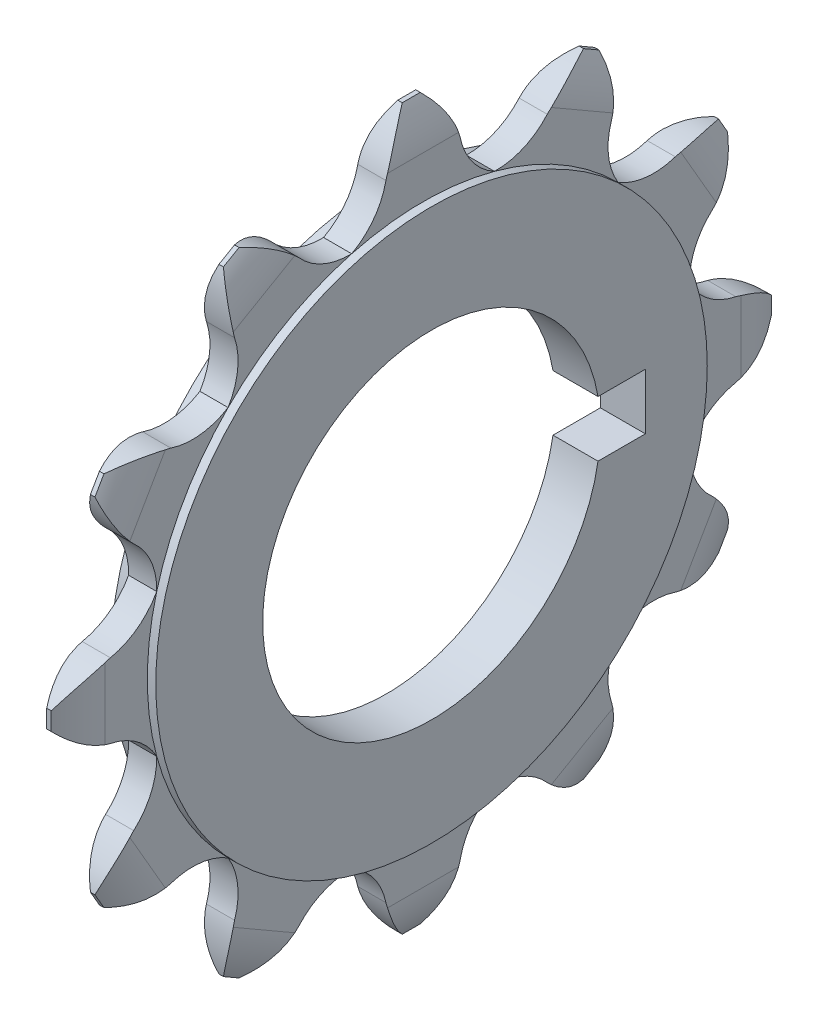
from build123d import *

# Parameters (mm, degrees)
BOSS_EXTRUDE1_DEPTH     = 3.175
CUT_EXTRUDE1_DEPTH      = 17.106309177
CUT_EXTRUDE1_DEPTH_BACK = 17.106309177
CIRPATTERN1_COUNT       = 12
SKETCH6_R               = 62.23
SKETCH6_R_2             = 38.1
BOSS_EXTRUDE2_DEPTH     = 5.08
SKETCH7_W               = 20.32
SKETCH7_H               = 12.621911528
CUT_EXTRUDE2_DEPTH      = 6.08
CUT_EXTRUDE2_DEPTH_BACK = 6.08


with BuildPart() as part:
    # Sketch4 → Boss-Extrude1 (new body, symmetric)
    with BuildSketch(Plane(origin=(0, 0, 0), x_dir=(0, 0, -1), z_dir=(1, 0, 0))):
        with BuildLine():
            Line((-2.032, 81.255567884), (2.032, 81.255567884))
            ThreePointArc((2.032, 81.255567884), (5.928090971, 76.340921265), (8.382, 70.56930046))
            ThreePointArc((8.382, 70.56930046), (11.0866932, 64.484669884), (16.106309177, 60.10956417))
            ThreePointArc((16.106309177, 60.10956417), (0, 62.23), (-16.106309177, 60.10956417))
            ThreePointArc((-16.106309177, 60.10956417), (-11.0866932, 64.484669884), (-8.382, 70.56930046))
            ThreePointArc((-8.382, 70.56930046), (-5.928090971, 76.340921265), (-2.032, 81.255567884))
        make_face()
    extrude(amount=BOSS_EXTRUDE1_DEPTH, both=True)

    # Sketch5 → Cut-Extrude1 (cut, two sides)
    with BuildSketch(Plane.XY) as cut_extrude1_sk:
        with BuildLine():
            Line((-0.508, 81.255567884), (0.508, 81.255567884))
            ThreePointArc((0.508, 81.255567884), (2.579341226, 76.096579157), (3.175, 70.56930046))
            Line((3.175, 70.56930046), (13.239002465, 70.56930046))
            Line((13.239002465, 70.56930046), (13.239002465, 94.490077883))
            Line((13.239002465, 94.490077883), (-20.321800896, 94.490077883))
            Line((-20.321800896, 94.490077883), (-20.321800896, 70.56930046))
            Line((-20.321800896, 70.56930046), (-3.175, 70.56930046))
            ThreePointArc((-3.175, 70.56930046), (-2.579341226, 76.096579157), (-0.508, 81.255567884))
        make_face()
    extrude(amount=CUT_EXTRUDE1_DEPTH, mode=Mode.SUBTRACT)
    extrude(cut_extrude1_sk.sketch, amount=-CUT_EXTRUDE1_DEPTH_BACK, mode=Mode.SUBTRACT)


with BuildPart() as cirpattern1_1:
    # CirPattern1: pattern copy
    add(part.part.rotate(Axis((0, 0, 0), (1, 0, 0)), 1 * 360 / CIRPATTERN1_COUNT))


with BuildPart() as cirpattern1_2:
    # CirPattern1: pattern copy
    add(part.part.rotate(Axis((0, 0, 0), (1, 0, 0)), 2 * 360 / CIRPATTERN1_COUNT))


with BuildPart() as cirpattern1_3:
    # CirPattern1: pattern copy
    add(part.part.rotate(Axis((0, 0, 0), (1, 0, 0)), 3 * 360 / CIRPATTERN1_COUNT))


with BuildPart() as cirpattern1_4:
    # CirPattern1: pattern copy
    add(part.part.rotate(Axis((0, 0, 0), (1, 0, 0)), 4 * 360 / CIRPATTERN1_COUNT))


with BuildPart() as cirpattern1_5:
    # CirPattern1: pattern copy
    add(part.part.rotate(Axis((0, 0, 0), (1, 0, 0)), 5 * 360 / CIRPATTERN1_COUNT))


with BuildPart() as cirpattern1_6:
    # CirPattern1: pattern copy
    add(part.part.rotate(Axis((0, 0, 0), (1, 0, 0)), 6 * 360 / CIRPATTERN1_COUNT))


with BuildPart() as cirpattern1_7:
    # CirPattern1: pattern copy
    add(part.part.rotate(Axis((0, 0, 0), (1, 0, 0)), 7 * 360 / CIRPATTERN1_COUNT))


with BuildPart() as cirpattern1_8:
    # CirPattern1: pattern copy
    add(part.part.rotate(Axis((0, 0, 0), (1, 0, 0)), 8 * 360 / CIRPATTERN1_COUNT))


with BuildPart() as cirpattern1_9:
    # CirPattern1: pattern copy
    add(part.part.rotate(Axis((0, 0, 0), (1, 0, 0)), 9 * 360 / CIRPATTERN1_COUNT))


with BuildPart() as cirpattern1_10:
    # CirPattern1: pattern copy
    add(part.part.rotate(Axis((0, 0, 0), (1, 0, 0)), 10 * 360 / CIRPATTERN1_COUNT))


with BuildPart() as cirpattern1_11:
    # CirPattern1: pattern copy
    add(part.part.rotate(Axis((0, 0, 0), (1, 0, 0)), 11 * 360 / CIRPATTERN1_COUNT))


with BuildPart() as part_1:
    add(part.part)

    add(cirpattern1_1.part)  # Boss-Extrude2 merges CirPattern1_1

    add(cirpattern1_2.part)  # Boss-Extrude2 merges CirPattern1_2

    add(cirpattern1_3.part)  # Boss-Extrude2 merges CirPattern1_3

    add(cirpattern1_4.part)  # Boss-Extrude2 merges CirPattern1_4

    add(cirpattern1_5.part)  # Boss-Extrude2 merges CirPattern1_5

    add(cirpattern1_6.part)  # Boss-Extrude2 merges CirPattern1_6

    add(cirpattern1_7.part)  # Boss-Extrude2 merges CirPattern1_7

    add(cirpattern1_8.part)  # Boss-Extrude2 merges CirPattern1_8

    add(cirpattern1_9.part)  # Boss-Extrude2 merges CirPattern1_9

    add(cirpattern1_10.part)  # Boss-Extrude2 merges CirPattern1_10

    add(cirpattern1_11.part)  # Boss-Extrude2 merges CirPattern1_11
    # Sketch6 → Boss-Extrude2 (add, symmetric)
    with BuildSketch(Plane(origin=(0, 0, 0), x_dir=(0, 0, -1), z_dir=(1, 0, 0))):
        Circle(SKETCH6_R)
        Circle(SKETCH6_R_2, mode=Mode.SUBTRACT)
    extrude(amount=BOSS_EXTRUDE2_DEPTH, both=True)

    # Sketch7 → Cut-Extrude2 (cut, two sides)
    with BuildSketch(Plane(origin=(0, 0, 0), x_dir=(0, 0, -1), z_dir=(1, 0, 0))) as cut_extrude2_sk:
        with Locations((38.1, 0)):
            Rectangle(SKETCH7_W, SKETCH7_H)
    extrude(amount=CUT_EXTRUDE2_DEPTH, mode=Mode.SUBTRACT)
    extrude(cut_extrude2_sk.sketch, amount=-CUT_EXTRUDE2_DEPTH_BACK, mode=Mode.SUBTRACT)


solid = part_1.part
